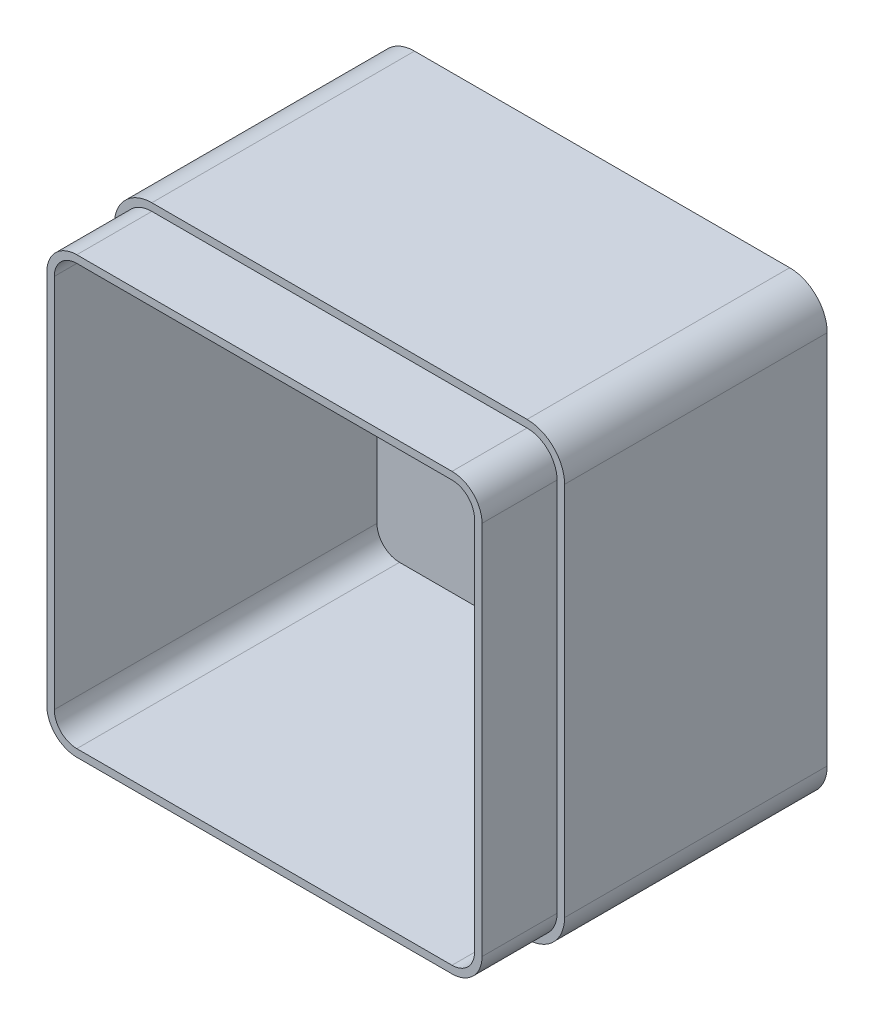
from build123d import *

# Parameters (mm, degrees)
SKETCH1_W           = 120
SKETCH1_H           = 120
BOSS_EXTRUDE1_DEPTH = 90
FILLET1_R           = 10
SHELL1_T            = -4
SKETCH2_OUTSIDE_W   = 160.418
SKETCH2_OUTSIDE_H   = 160.418
CUT_EXTRUDE2_DEPTH  = 20


with BuildPart() as part:
    # Sketch1 → Boss-Extrude1 (new body)
    with BuildSketch(Plane.XY):
        with Locations((30.230179028, -23.017902813)):
            Rectangle(SKETCH1_W, SKETCH1_H)
    extrude(amount=BOSS_EXTRUDE1_DEPTH)

    # Fillet1
    fillet1_edges = [part.edges().sort_by_distance(p)[0] for p in [
        (-29.769820972, 36.982097187, 45),
        (90.230179028, 36.982097187, 45),
        (90.230179028, -83.017902813, 45),
        (-29.769820972, -83.017902813, 45),
    ]]
    fillet(fillet1_edges, radius=FILLET1_R)

    # Shell1
    shell1_openings = [part.faces().sort_by_distance(p)[0] for p in [
        (30.230179028, -23.017902813, 90),
    ]]
    offset(amount=SHELL1_T, openings=shell1_openings, kind=Kind.INTERSECTION)

    # Sketch2 outside → Cut-Extrude2 (cut)
    with BuildSketch(Plane.XY.offset(90)):
        with Locations((30.23, -23.018)):
            Rectangle(SKETCH2_OUTSIDE_W, SKETCH2_OUTSIDE_H)
        with BuildLine():
            Line((-27.769820972, 26.982097187), (-27.769820972, -73.017902813))
            ThreePointArc((-27.769820972, -73.017902813), (-25.426675221, -78.674757063), (-19.769820972, -81.017902813))
            Line((-19.769820972, -81.017902813), (80.230179028, -81.017902813))
            ThreePointArc((80.230179028, -81.017902813), (85.887033278, -78.674757063), (88.230179028, -73.017902813))
            Line((88.230179028, -73.017902813), (88.230179028, 26.982097187))
            ThreePointArc((88.230179028, 26.982097187), (85.887033278, 32.638951436), (80.230179028, 34.982097187))
            Line((80.230179028, 34.982097187), (-19.769820972, 34.982097187))
            ThreePointArc((-19.769820972, 34.982097187), (-25.426675221, 32.638951436), (-27.769820972, 26.982097187))
        make_face(mode=Mode.SUBTRACT)
    extrude(amount=-CUT_EXTRUDE2_DEPTH, mode=Mode.SUBTRACT)


solid = part.part
